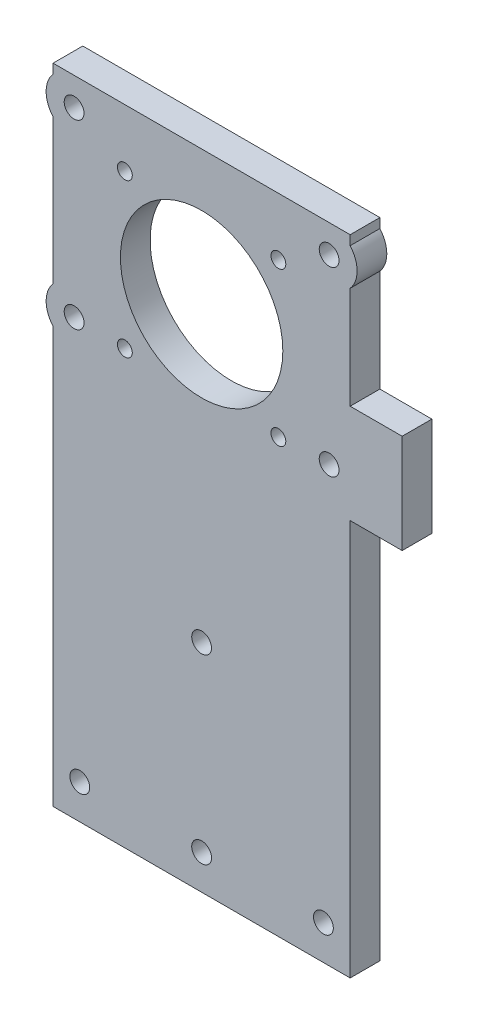
from build123d import *

# Parameters (mm, degrees)
SKETCH_1_W          = 60
SKETCH_1_H          = 124
EXTRUDE_1_DEPTH     = 6
SKETCH_2_R          = 16.4
SKETCH_2_R_2        = 1.5
CUT_EXTRUDE_1_DEPTH = 7
SKETCH_4_R          = 2
CUT_EXTRUDE_2_DEPTH = 7
SKETCH_5_W          = 60
SKETCH_5_H          = 6
EXTRUDE_2_DEPTH     = 6
SKETCH_6_R          = 2
CUT_EXTRUDE_3_DEPTH = 7
SKETCH_7_R          = 5.65
SKETCH_7_R_2        = 2
SKETCH_7_W          = 10.5
SKETCH_7_H          = 20
EXTRUDE_3_DEPTH     = 6


with BuildPart() as part:
    # Эскиз1 → Бобышка-Вытянуть1 (new body)
    with BuildSketch(Plane.XY):
        Rectangle(SKETCH_1_W, SKETCH_1_H)
    extrude(amount=EXTRUDE_1_DEPTH)

    # Эскиз2 → Вырез-Вытянуть1 (cut, through all)
    with BuildSketch(Plane.XY.offset(6)):
        with Locations((0, 40.85)):
            Circle(SKETCH_2_R)
        with Locations((-15.5, 56.35)):
            Circle(SKETCH_2_R_2)
        with Locations((15.5, 56.35)):
            Circle(SKETCH_2_R_2)
        with Locations((15.5, 25.35)):
            Circle(SKETCH_2_R_2)
        with Locations((-15.5, 25.35)):
            Circle(SKETCH_2_R_2)
    extrude(amount=-CUT_EXTRUDE_1_DEPTH, mode=Mode.SUBTRACT)

    # Эскиз4 → Вырез-Вытянуть2 (cut, through all)
    with BuildSketch(Plane.XY.offset(6)):
        with Locations((-24.6, -55)):
            Circle(SKETCH_4_R)
        with Locations((0, -55)):
            Circle(SKETCH_4_R)
        with Locations((24.6, -55)):
            Circle(SKETCH_4_R)
    extrude(amount=-CUT_EXTRUDE_2_DEPTH, mode=Mode.SUBTRACT)

    # Эскиз5 → Бобышка-Вытянуть2 (add)
    with BuildSketch(Plane(origin=(0, 62, 0), x_dir=(1, 0, 0), z_dir=(0, 1, 0))):
        with Locations((0, -3)):
            Rectangle(SKETCH_5_W, SKETCH_5_H)
    extrude(amount=EXTRUDE_2_DEPTH)

    # Эскиз6 → Вырез-Вытянуть3 (cut, through all)
    with BuildSketch(Plane(origin=(0, 0, 0), x_dir=(-1, 0, 0), z_dir=(0, 0, -1))):
        with Locations((-25.75, 62.35)):
            Circle(SKETCH_6_R)
        with Locations((25.75, 62.35)):
            Circle(SKETCH_6_R)
        with Locations((25.75, 25.7)):
            Circle(SKETCH_6_R)
        with Locations((-25.75, 25.7)):
            Circle(SKETCH_6_R)
        with Locations((0, -18.3)):
            Circle(SKETCH_6_R)
    extrude(amount=-CUT_EXTRUDE_3_DEPTH, mode=Mode.SUBTRACT)

    # Эскиз7 → Бобышка-Вытянуть3 (add)
    with BuildSketch(Plane(origin=(0, 0, 0), x_dir=(-1, 0, 0), z_dir=(0, 0, -1))):
        with Locations((-25.75, 62.35)):
            Circle(SKETCH_7_R)
        with Locations((-25.75, 62.35)):
            Circle(SKETCH_7_R_2, mode=Mode.SUBTRACT)
        with Locations((25.75, 62.35)):
            Circle(SKETCH_7_R)
        with Locations((25.75, 62.35)):
            Circle(SKETCH_7_R_2, mode=Mode.SUBTRACT)
        with Locations((25.75, 25.7)):
            Circle(SKETCH_7_R)
        with Locations((25.75, 25.7)):
            Circle(SKETCH_7_R_2, mode=Mode.SUBTRACT)
        with Locations((-35.25, 28)):
            Rectangle(SKETCH_7_W, SKETCH_7_H)
    extrude(amount=-EXTRUDE_3_DEPTH)


solid = part.part
